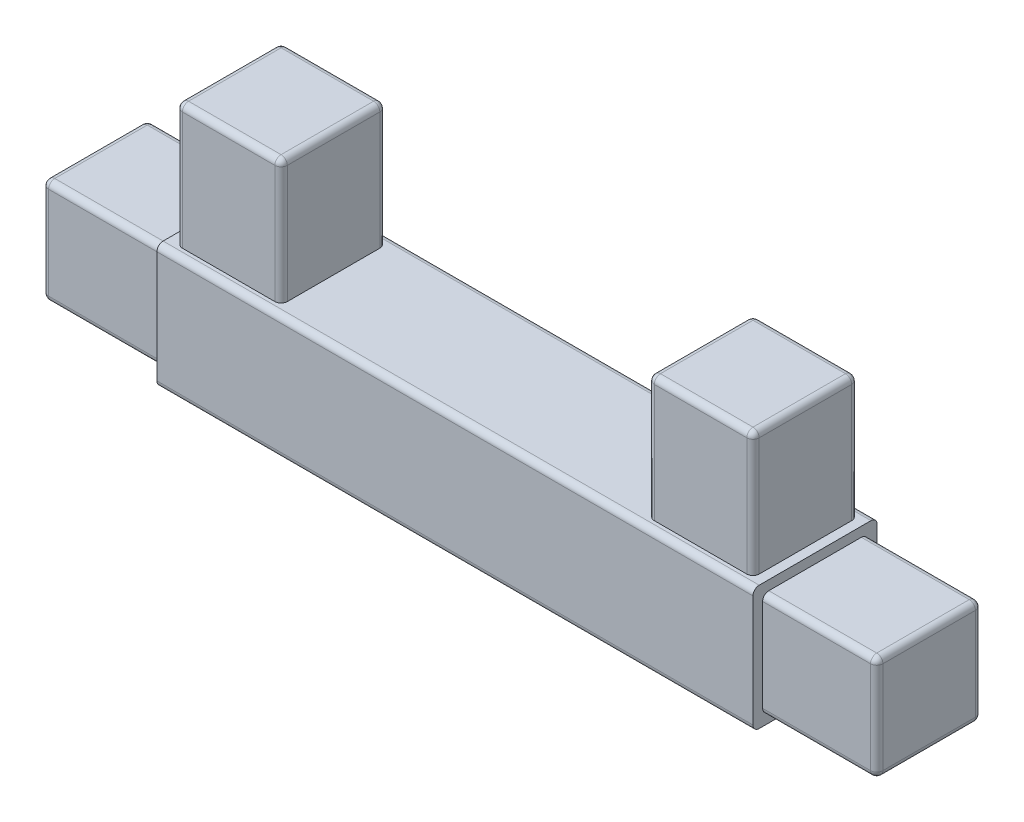
from build123d import *

# Parameters (mm, degrees)
SKETCH1_W           = 96
SKETCH1_H           = 20
BOSS_EXTRUDE1_DEPTH = 20
BOSS_EXTRUDE2_START = 1.55
SKETCH1_3_W         = 20
SKETCH1_3_H         = 16.9
SKETCH1_3_W_2       = 18.378378378
BOSS_EXTRUDE2_DEPTH = 16.9
SKETCH2_W           = 16.9
SKETCH2_H           = 16.9
BOSS_EXTRUDE3_DEPTH = 20
FILLET2_R           = 1


with BuildPart() as part:
    # Sketch1 → Boss-Extrude1 (new body)
    with BuildSketch(Plane(origin=(0, 0, 0), x_dir=(1, 0, 0), z_dir=(0, 1, 0))):
        Rectangle(SKETCH1_W, SKETCH1_H)
    extrude(amount=BOSS_EXTRUDE1_DEPTH)

    # Sketch1_3 → Boss-Extrude2 (add)
    with BuildSketch(Plane(origin=(0, 0, 0), x_dir=(1, 0, 0), z_dir=(0, 1, 0)).offset(BOSS_EXTRUDE2_START)):
        with Locations((-58, 0)):
            Rectangle(SKETCH1_3_W, SKETCH1_3_H)
        with Locations((57.189189189, 0)):
            Rectangle(SKETCH1_3_W_2, SKETCH1_3_H)
    extrude(amount=BOSS_EXTRUDE2_DEPTH)

    # Sketch2 → Boss-Extrude3 (add)
    with BuildSketch(Plane(origin=(0, 20, 0), x_dir=(1, 0, 0), z_dir=(0, 1, 0))):
        with Locations((38, 0)):
            Rectangle(SKETCH2_W, SKETCH2_H)
        with Locations((-38, 0)):
            Rectangle(SKETCH2_W, SKETCH2_H)
    extrude(amount=BOSS_EXTRUDE3_DEPTH)

    # Fillet2
    fillet2_edges = [part.edges().sort_by_distance(p)[0] for p in [
        (-58, 18.45, 8.45),
        (-46.45, 30, 8.45),
        (-46.45, 30, -8.45),
        (-38, 40, -8.45),
        (-46.45, 40, 0),
        (-38, 40, 8.45),
        (-29.55, 40, 0),
        (-29.55, 30, 8.45),
        (-29.55, 30, -8.45),
        (29.55, 30, -8.45),
        (29.55, 30, 8.45),
        (38, 40, -8.45),
        (29.55, 40, 0),
        (38, 40, 8.45),
        (46.45, 40, 0),
        (46.45, 30, -8.45),
        (46.45, 30, 8.45),
        (57.189189189, 1.55, -8.45),
        (0, 0, -10),
        (57.189189189, 18.45, -8.45),
        (66.378378378, 10, -8.45),
        (66.378378378, 18.45, 0),
        (66.378378378, 10, 8.45),
        (57.189189189, 1.55, 8.45),
        (66.378378378, 1.55, 0),
        (57.189189189, 18.45, 8.45),
        (0, 20, -10),
        (0, 0, 10),
        (0, 20, 10),
        (-58, 1.55, -8.45),
        (-68, 1.55, 0),
        (-58, 1.55, 8.45),
        (-68, 10, -8.45),
        (-58, 18.45, -8.45),
        (-68, 18.45, 0),
        (-68, 10, 8.45),
    ]]
    fillet(fillet2_edges, radius=FILLET2_R)


solid = part.part
